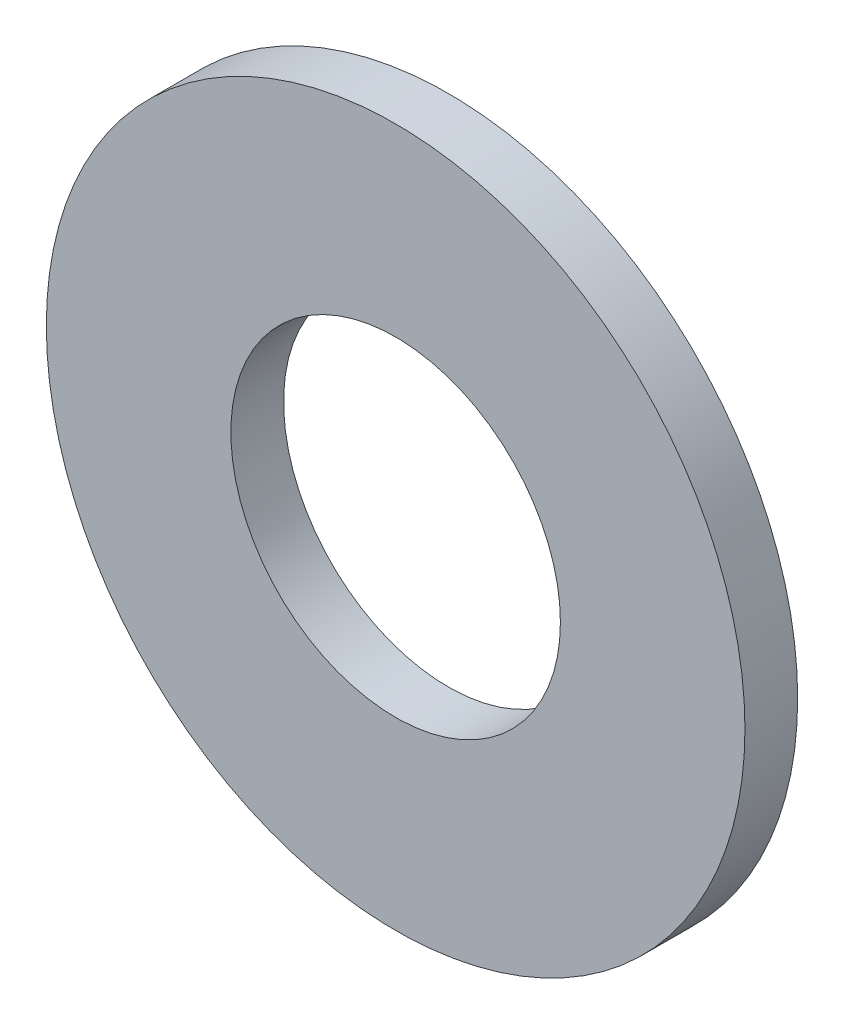
from build123d import *

# Parameters (mm, degrees)
SKETCH1_R           = 13.25
SKETCH1_R_2         = 6.25
BOSS_EXTRUDE1_DEPTH = 1


with BuildPart() as part:
    # Sketch1 → Boss-Extrude1 (new body, symmetric)
    with BuildSketch(Plane.XY):
        Circle(SKETCH1_R)
        Circle(SKETCH1_R_2, mode=Mode.SUBTRACT)
    extrude(amount=BOSS_EXTRUDE1_DEPTH, both=True)


solid = part.part
